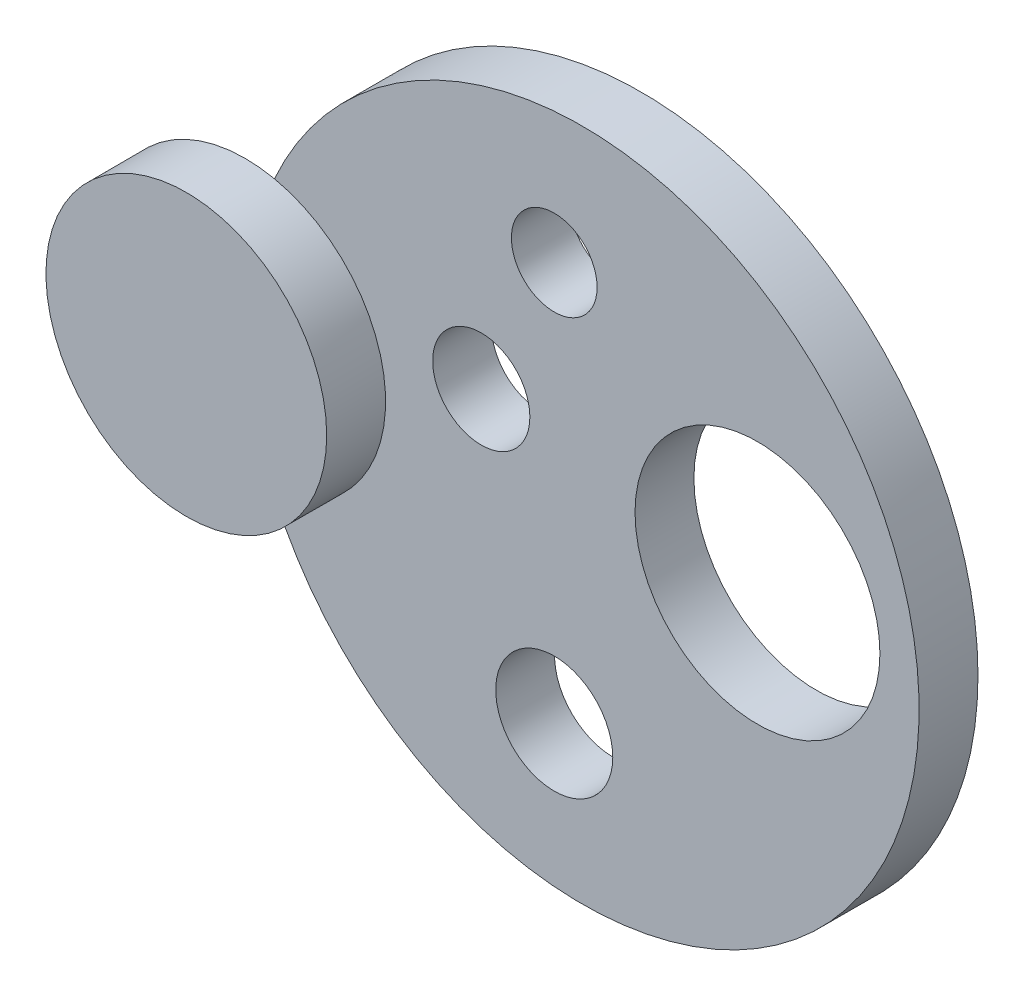
from build123d import *

# Parameters (mm, degrees)
CROQUIS1_R              = 57.226702921
CROQUIS1_R_2            = 7.277968804
CROQUIS1_R_3            = 9.940183118
CROQUIS1_R_4            = 20.796607535
SALIENTE_EXTRUIR1_DEPTH = 10
CROQUIS2_R              = 23.842859528
SALIENTE_EXTRUIR2_DEPTH = 10
CROQUIS3_R              = 8.254589986
CORTAR_EXTRUIR1_DEPTH   = 10


with BuildPart() as part:
    # Croquis1 → Saliente-Extruir1 (new body)
    with BuildSketch(Plane.XY):
        Circle(CROQUIS1_R)
        with Locations((-4.741989664, 34.759410431)):
            Circle(CROQUIS1_R_2, mode=Mode.SUBTRACT)
        with Locations((-4.741989664, -33.045918367)):
            Circle(CROQUIS1_R_3, mode=Mode.SUBTRACT)
        with Locations((29.772636186, 4.89569161)):
            Circle(CROQUIS1_R_4, mode=Mode.SUBTRACT)
    extrude(amount=SALIENTE_EXTRUIR1_DEPTH)

    # Croquis2 → Saliente-Extruir2 (add)
    with BuildSketch(Plane.XY.offset(10)):
        with Locations((-57.226702921, 0)):
            Circle(CROQUIS2_R)
    extrude(amount=SALIENTE_EXTRUIR2_DEPTH)

    # Croquis3 → Cortar-Extruir1 (cut)
    with BuildSketch(Plane.XY.offset(10)):
        with Locations((-17.135779728, 9.968610226)):
            Circle(CROQUIS3_R)
    extrude(amount=-CORTAR_EXTRUIR1_DEPTH, mode=Mode.SUBTRACT)


solid = part.part
